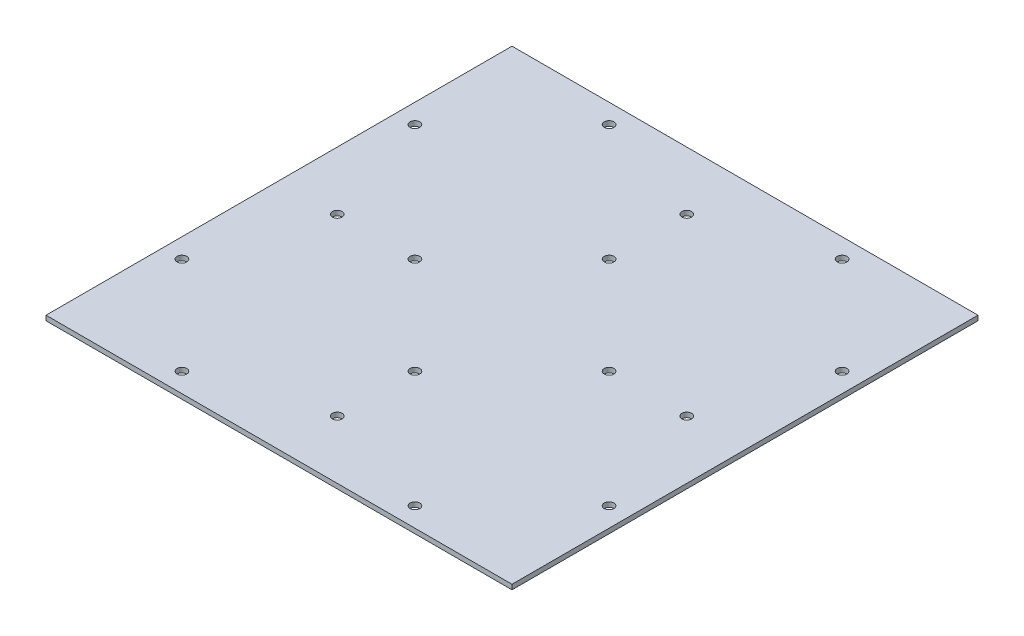
from build123d import *

# Parameters (mm, degrees)
SKETCH1_W           = 304.8
SKETCH1_H           = 304.8
BOSS_EXTRUDE1_DEPTH = 3.175
CUT_EXTRUDE1_REACH  = 217.55
SKETCH2_R           = 3.175
CIRPATTERN1_COUNT   = 4
CUT_EXTRUDE2_REACH  = 217.55
SKETCH4_R           = 3.175
CIRPATTERN2_COUNT   = 4


with BuildPart() as part:
    # Sketch1 → Boss-Extrude1 (new body)
    with BuildSketch(Plane(origin=(0, 0, 0), x_dir=(1, 0, 0), z_dir=(0, 1, 0))):
        Rectangle(SKETCH1_W, SKETCH1_H)
    extrude(amount=BOSS_EXTRUDE1_DEPTH)

    # Sketch2 → Cut-Extrude1 (cut, up to next)
    with BuildSketch(Plane(origin=(0, 3.175, 0), x_dir=(1, 0, 0), z_dir=(0, 1, 0)), mode=Mode.PRIVATE) as cut_extrude1_sk1:
        with Locations((0, 114.3)):
            Circle(SKETCH2_R)
    cut_extrude1_tool1 = extrude(cut_extrude1_sk1.sketch, amount=-CUT_EXTRUDE1_REACH, mode=Mode.PRIVATE) & part.part
    # Sketch2 → Cut-Extrude1 (cut, up to next)
    with BuildSketch(Plane(origin=(0, 3.175, 0), x_dir=(1, 0, 0), z_dir=(0, 1, 0)), mode=Mode.PRIVATE) as cut_extrude1_sk2:
        with Locations((0, 63.5)):
            Circle(SKETCH2_R)
    cut_extrude1_tool2 = extrude(cut_extrude1_sk2.sketch, amount=-CUT_EXTRUDE1_REACH, mode=Mode.PRIVATE) & part.part
    cut_extrude1_1 = cut_extrude1_tool1.solids().sort_by_distance((0, 3.175, -114.3))[0]
    add(cut_extrude1_1, mode=Mode.SUBTRACT)
    cut_extrude1_2 = cut_extrude1_tool2.solids().sort_by_distance((0, 3.175, -63.5))[0]
    add(cut_extrude1_2, mode=Mode.SUBTRACT)
    cut_extrude1 = cut_extrude1_1 + cut_extrude1_2  # Cut-Extrude1 as one shape, for the pattern or mirror that repeats it

    # CirPattern1: Cut-Extrude1 ×4 about axis
    cirpattern1_axis = Axis((0, 3.175, 0), (0, 1, 0))
    for i in range(1, CIRPATTERN1_COUNT):
        add(cut_extrude1.rotate(cirpattern1_axis, i * 360 / CIRPATTERN1_COUNT), mode=Mode.SUBTRACT)

    # Sketch4 → Cut-Extrude2 (cut, up to next)
    with BuildSketch(Plane(origin=(0, 3.175, 0), x_dir=(1, 0, 0), z_dir=(0, 1, 0)), mode=Mode.PRIVATE) as cut_extrude2_sk1:
        with Locations((-76.2, 139.7)):
            Circle(SKETCH4_R)
    cut_extrude2_tool1 = extrude(cut_extrude2_sk1.sketch, amount=-CUT_EXTRUDE2_REACH, mode=Mode.PRIVATE) & part.part
    # Sketch4 → Cut-Extrude2 (cut, up to next)
    with BuildSketch(Plane(origin=(0, 3.175, 0), x_dir=(1, 0, 0), z_dir=(0, 1, 0)), mode=Mode.PRIVATE) as cut_extrude2_sk2:
        with Locations((76.2, 139.7)):
            Circle(SKETCH4_R)
    cut_extrude2_tool2 = extrude(cut_extrude2_sk2.sketch, amount=-CUT_EXTRUDE2_REACH, mode=Mode.PRIVATE) & part.part
    cut_extrude2_1 = cut_extrude2_tool1.solids().sort_by_distance((-76.2, 3.175, -139.7))[0]
    add(cut_extrude2_1, mode=Mode.SUBTRACT)
    cut_extrude2_2 = cut_extrude2_tool2.solids().sort_by_distance((76.2, 3.175, -139.7))[0]
    add(cut_extrude2_2, mode=Mode.SUBTRACT)
    cut_extrude2 = cut_extrude2_1 + cut_extrude2_2  # Cut-Extrude2 as one shape, for the pattern or mirror that repeats it

    # CirPattern2: Cut-Extrude2 ×4 about axis
    cirpattern2_axis = Axis((0, 3.175, 0), (0, 1, 0))
    for i in range(1, CIRPATTERN2_COUNT):
        add(cut_extrude2.rotate(cirpattern2_axis, i * 360 / CIRPATTERN2_COUNT), mode=Mode.SUBTRACT)


solid = part.part
